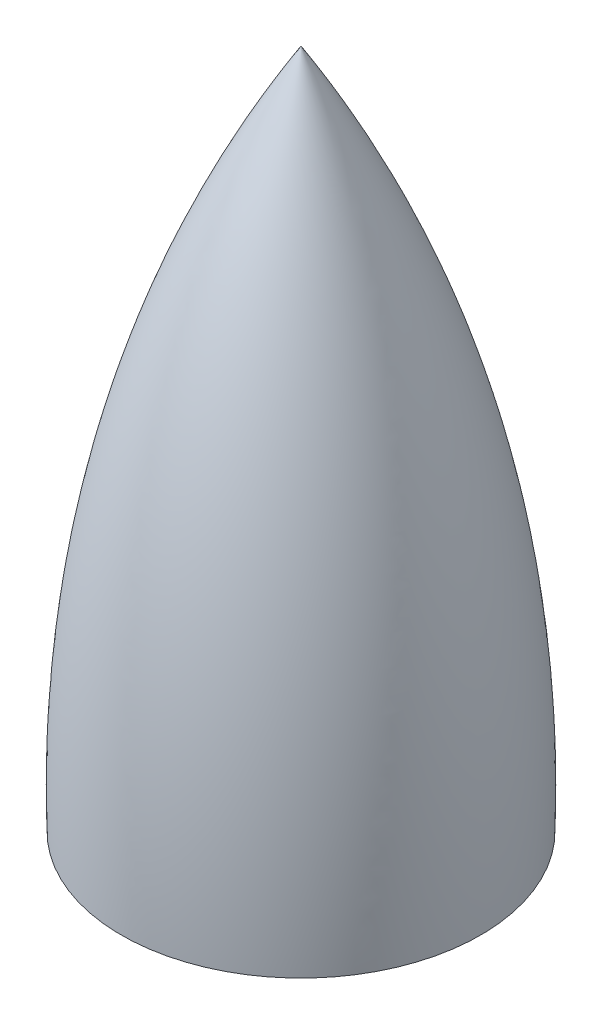
from build123d import *


with BuildPart() as part:
    # Sketch2 → Revolve2 (revolve)
    with BuildSketch(Plane.XY):
        with BuildLine():
            Line((-101.6, 0), (-104.775, 0))
            add(Edge.make_bspline(
                [(-104.775, 0), (-110.968397663, 215.541081293), (0, 396.861364613)],
                knots=[0, 0, 0, 1, 1, 1], degree=2))
            Line((0, 396.861364613), (0, 393.686364613))
            add(Edge.make_bspline(
                [(-101.6, 0), (-107.046011686, 212.987606476), (0, 393.686364613)],
                knots=[0, 0, 0, 1, 1, 1], degree=2))
        make_face()
    revolve(axis=Axis((0, 0, 0), (0, 1, 0)))


solid = part.part
